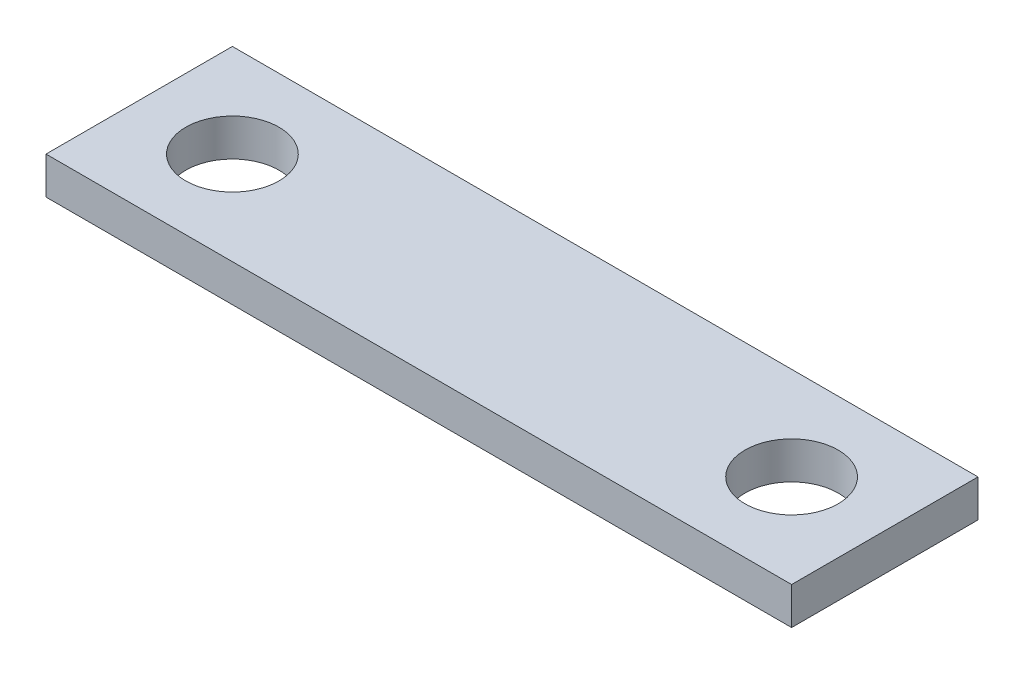
from build123d import *

# Parameters (mm, degrees)
SKETCH1_W           = 20
SKETCH1_H           = 5
SKETCH1_R           = 1.25
BOSS_EXTRUDE1_DEPTH = 1


with BuildPart() as part:
    # Sketch1 → Boss-Extrude1 (new body)
    with BuildSketch(Plane(origin=(0, 0, 0), x_dir=(1, 0, 0), z_dir=(0, 1, 0))):
        Rectangle(SKETCH1_W, SKETCH1_H)
        with Locations((-7.5, 0)):
            Circle(SKETCH1_R, mode=Mode.SUBTRACT)
        with Locations((7.5, 0)):
            Circle(SKETCH1_R, mode=Mode.SUBTRACT)
    extrude(amount=BOSS_EXTRUDE1_DEPTH)


solid = part.part
